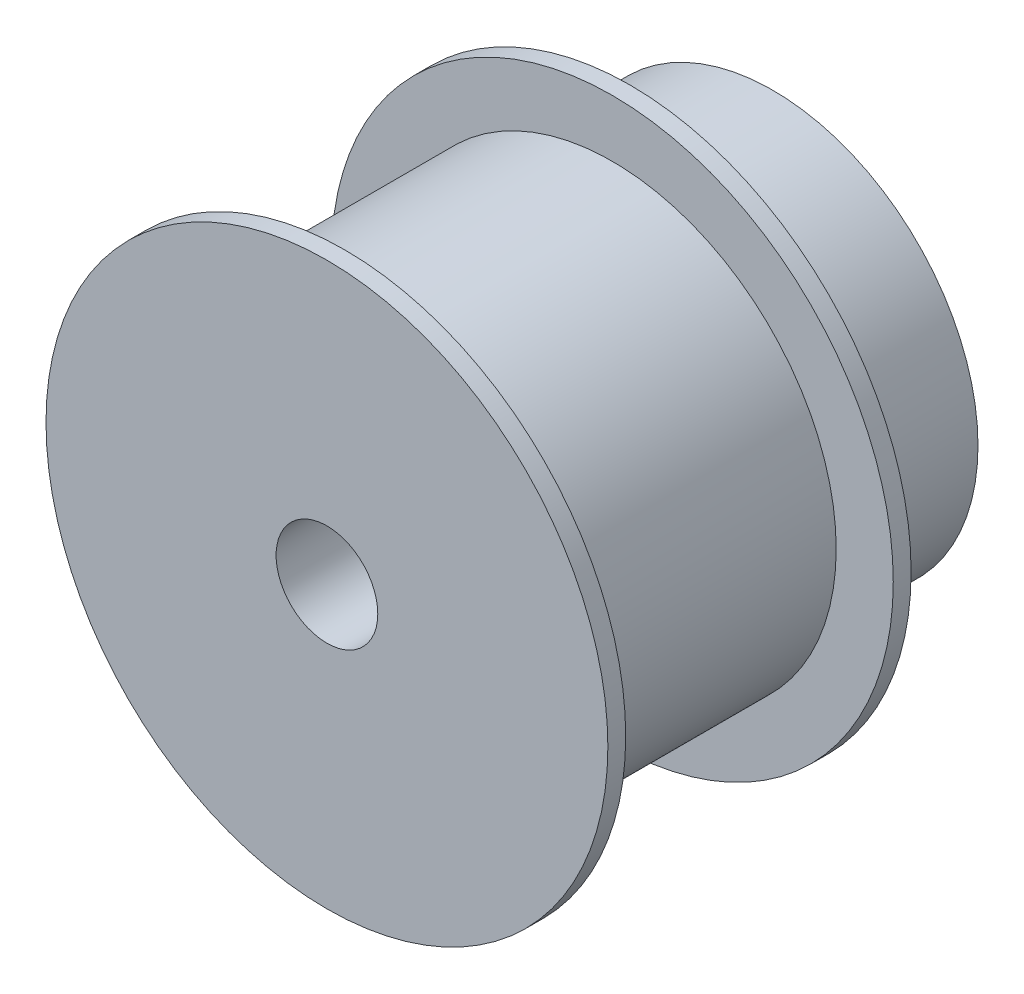
from build123d import *


with BuildPart() as part:
    # Esquisse1 → Révolution1 (revolve)
    with BuildSketch(Plane(origin=(0, 0, 0), x_dir=(1, 0, 0), z_dir=(0, 1, 0))):
        Polygon((15.75, -9), (15.75, -8), (11.5, -8), (11.5, 0), (2.85, 0), (2.85, -25), (15.75, -25), (15.75, -24), (12.55, -24), (12.55, -9), align=None)
    revolve(axis=Axis((0, 0, 0), (0, 0, 1)))


solid = part.part
